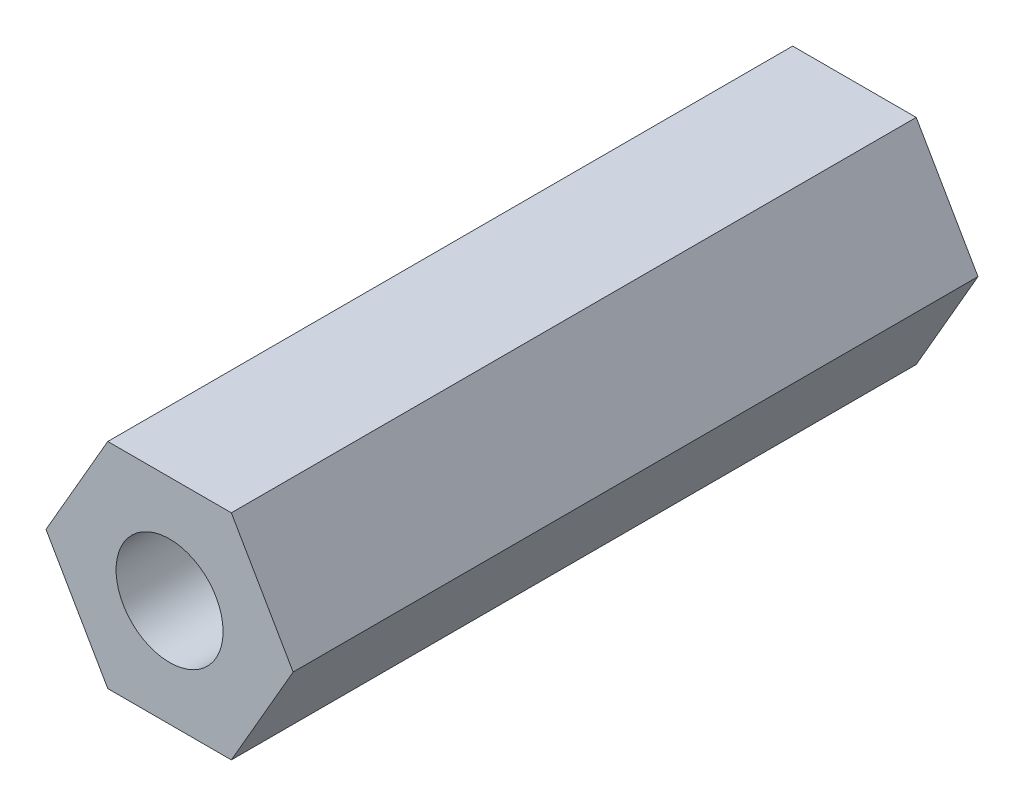
from build123d import *

# Parameters (mm, degrees)
SKETCH1_R           = 1.25
BOSS_EXTRUDE1_DEPTH = 16


with BuildPart() as part:
    # Sketch1 → Boss-Extrude1 (new body)
    with BuildSketch(Plane.XY):
        Polygon((2.886751346, 0), (1.443375673, 2.5), (-1.443375673, 2.5), (-2.886751346, 0), (-1.443375673, -2.5), (1.443375673, -2.5), align=None)
        Circle(SKETCH1_R, mode=Mode.SUBTRACT)
    extrude(amount=BOSS_EXTRUDE1_DEPTH)


solid = part.part
